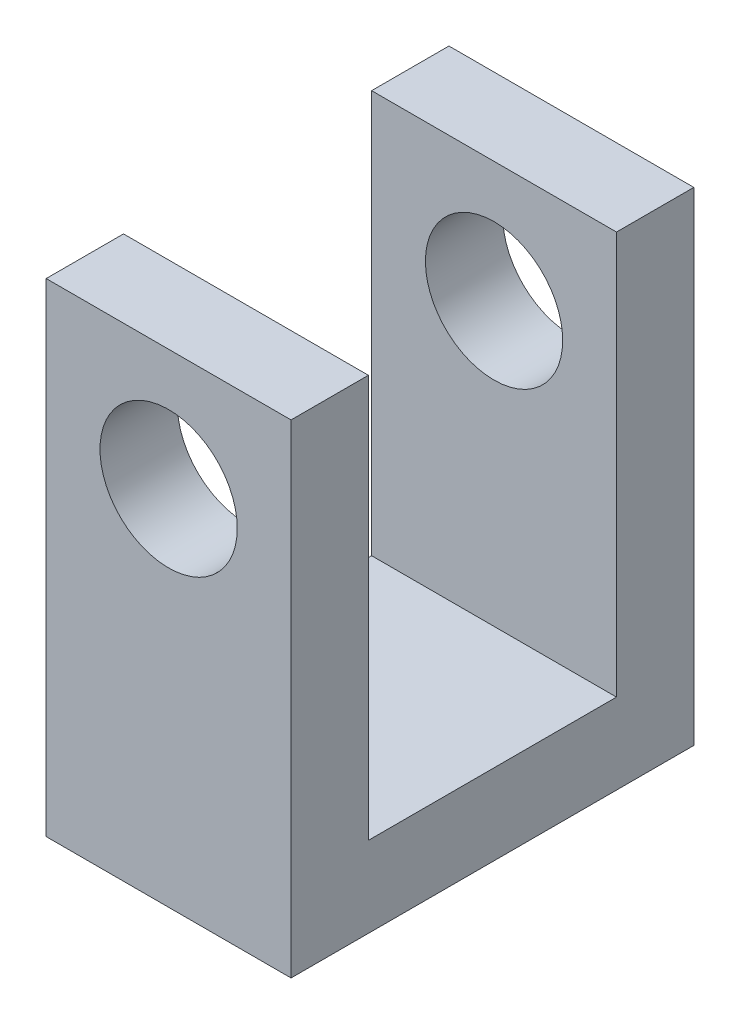
from build123d import *

# Parameters (mm, degrees)
SKETCH1_W                 = 4.826
SKETCH1_H                 = 7.9375
BOSS_EXTRUDE1_DEPTH       = 9.525
SKETCH2_W                 = 4.826
SKETCH2_H                 = 4.8895
CUT_EXTRUDE1_DEPTH        = 7.9375
F_6_32_TAPPED_HOLE1_D     = 2.7051
F_6_32_TAPPED_HOLE1_DEPTH = 9.398


with BuildPart() as part:
    # Sketch1 → Boss-Extrude1 (new body)
    with BuildSketch(Plane(origin=(0, 0, 0), x_dir=(1, 0, 0), z_dir=(0, 1, 0))):
        Rectangle(SKETCH1_W, SKETCH1_H)
    extrude(amount=BOSS_EXTRUDE1_DEPTH)

    # Sketch2 → Cut-Extrude1 (cut)
    with BuildSketch(Plane(origin=(0, 9.525, 0), x_dir=(1, 0, 0), z_dir=(0, 1, 0))):
        Rectangle(SKETCH2_W, SKETCH2_H)
    extrude(amount=-CUT_EXTRUDE1_DEPTH, mode=Mode.SUBTRACT)

    # #6-32 Tapped Hole1
    with Locations(Plane.XY.offset(3.96875)):
        with Locations((0, 7.14375)):
            Hole(F_6_32_TAPPED_HOLE1_D / 2, depth=F_6_32_TAPPED_HOLE1_DEPTH)


solid = part.part
